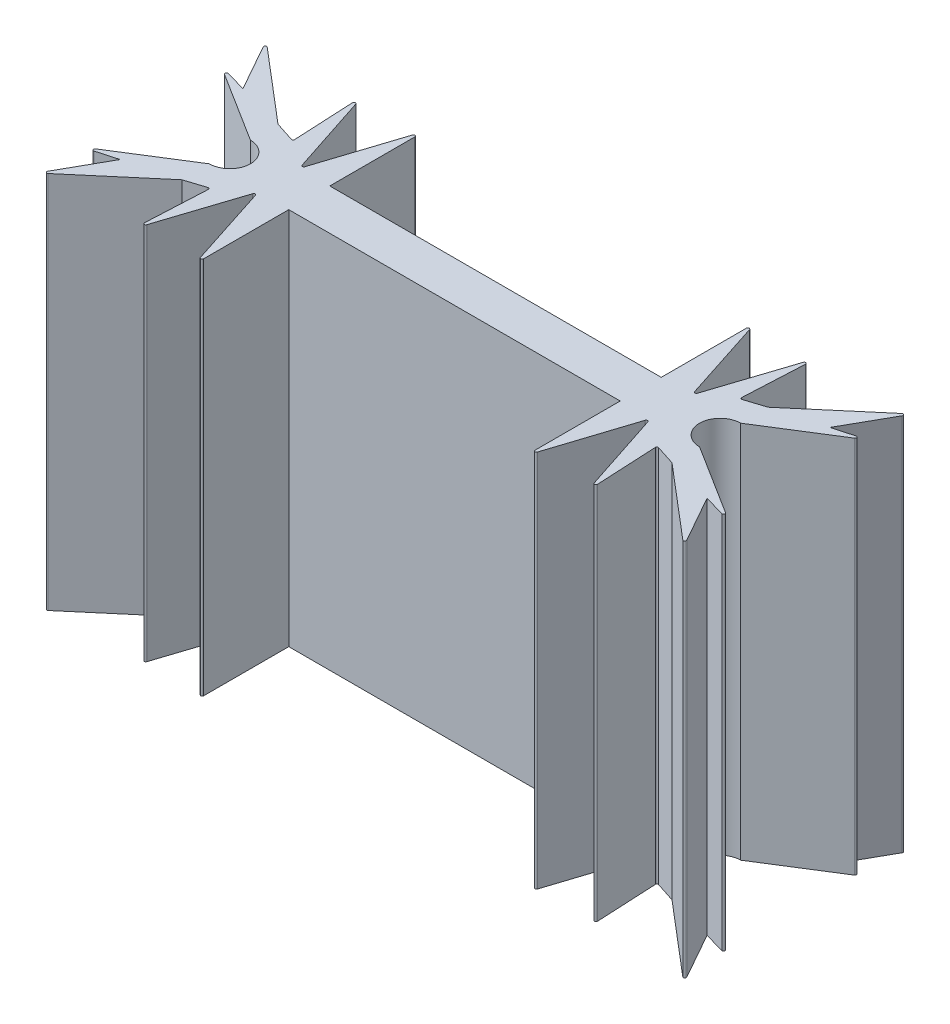
from build123d import *

# Parameters (mm, degrees)
EXTRUDE_1_DEPTH = 26.4


with BuildPart() as part:
    # Эскиз1 → Бобышка-Вытянуть1 (new body)
    with BuildSketch(Plane(origin=(0, 0, 0), x_dir=(1, 0, 0), z_dir=(0, 1, 0))):
        with BuildLine():
            Line((0, -7.366273292), (0, -1.430737225))
            Line((0, -1.430737225), (-23.119998808, -1.430737225))
            Line((-23.119998808, -1.430737225), (-23.119998808, -7.366273292))
            ThreePointArc((-23.119998808, -7.366273292), (-23.204411997, -7.465051079), (-23.315139834, -7.397065907))
            Line((-23.315139834, -7.397065907), (-25.151536602, -1.723086212))
            ThreePointArc((-25.151536602, -1.723086212), (-25.246516215, -1.653878958), (-25.341718752, -1.722779233))
            Line((-25.341718752, -1.722779233), (-27.163713043, -7.290838427))
            ThreePointArc((-27.163713043, -7.290838427), (-27.276953731, -7.358068766), (-27.358630238, -7.254761845))
            Line((-27.358630238, -7.254761845), (-27.147073457, -3.009330281))
            ThreePointArc((-27.147073457, -3.009330281), (-27.186129834, -2.924974677), (-27.277742143, -2.909212268))
            Line((-27.277742143, -2.909212268), (-28.656433819, -3.355429045))
            Line((-28.656433819, -3.355429045), (-33.693480219, -7.637416988))
            ThreePointArc((-33.693480219, -7.637416988), (-33.821863766, -7.638385786), (-33.84539196, -7.51217288))
            Line((-33.84539196, -7.51217288), (-32.027666378, -4.283069467))
            Line((-32.027666378, -4.283069467), (-33.457933536, -4.683052776))
            ThreePointArc((-33.457933536, -4.683052776), (-33.57629105, -4.627262362), (-33.538118808, -4.502106653))
            Line((-33.538118808, -4.502106653), (-28.656434415, -1.430737225))
            ThreePointArc((-28.656434415, -1.430737225), (-27.22569719, 0), (-28.656434415, 1.430737225))
            Line((-28.656434415, 1.430737225), (-33.538118808, 4.502106653))
            ThreePointArc((-33.538118808, 4.502106653), (-33.57629105, 4.627262362), (-33.457933536, 4.683052776))
            Line((-33.457933536, 4.683052776), (-32.027666378, 4.283069467))
            Line((-32.027666378, 4.283069467), (-33.84539196, 7.51217288))
            ThreePointArc((-33.84539196, 7.51217288), (-33.821862569, 7.638384319), (-33.693480241, 7.637416132))
            Line((-33.693480241, 7.637416132), (-28.656433494, 3.355428597))
            Line((-28.656433494, 3.355428597), (-27.277741782, 2.909211931))
            ThreePointArc((-27.277741782, 2.909211931), (-27.186129475, 2.924974348), (-27.147073104, 3.009329955))
            Line((-27.147073104, 3.009329955), (-27.358630229, 7.254761502))
            ThreePointArc((-27.358630229, 7.254761502), (-27.27695373, 7.35806843), (-27.163713037, 7.2908381))
            Line((-27.163713037, 7.2908381), (-25.341718295, 1.722779053))
            ThreePointArc((-25.341718295, 1.722779053), (-25.246515752, 1.653878786), (-25.151536145, 1.723086048))
            Line((-25.151536145, 1.723086048), (-23.315139837, 7.397065891))
            ThreePointArc((-23.315139837, 7.397065891), (-23.204412005, 7.465051072), (-23.119998808, 7.366273292))
            Line((-23.119998808, 7.366273292), (-23.119998808, 1.430737225))
            Line((-23.119998808, 1.430737225), (0, 1.430737225))
            Line((0, 1.430737225), (0, 7.366273292))
            ThreePointArc((0, 7.366273292), (0.084413196, 7.465051072), (0.195141029, 7.397065891))
            Line((0.195141029, 7.397065891), (2.031537337, 1.723086048))
            ThreePointArc((2.031537337, 1.723086048), (2.126516944, 1.653878786), (2.221719487, 1.722779053))
            Line((2.221719487, 1.722779053), (4.043714229, 7.2908381))
            ThreePointArc((4.043714229, 7.2908381), (4.156954922, 7.35806843), (4.238631421, 7.254761502))
            Line((4.238631421, 7.254761502), (4.027074296, 3.009329955))
            ThreePointArc((4.027074296, 3.009329955), (4.066130667, 2.924974348), (4.157742974, 2.909211931))
            Line((4.157742974, 2.909211931), (5.536434686, 3.355428597))
            Line((5.536434686, 3.355428597), (10.573481433, 7.637416132))
            ThreePointArc((10.573481433, 7.637416132), (10.701863761, 7.638384319), (10.725393152, 7.51217288))
            Line((10.725393152, 7.51217288), (8.90766757, 4.283069467))
            Line((8.90766757, 4.283069467), (10.337934728, 4.683052776))
            ThreePointArc((10.337934728, 4.683052776), (10.456292242, 4.627262362), (10.41812, 4.502106653))
            Line((10.41812, 4.502106653), (5.536435606, 1.430737225))
            ThreePointArc((5.536435606, 1.430737225), (4.105698382, 0), (5.536435606, -1.430737225))
            Line((5.536435606, -1.430737225), (10.41812, -4.502106653))
            ThreePointArc((10.41812, -4.502106653), (10.456292242, -4.627262362), (10.337934728, -4.683052776))
            Line((10.337934728, -4.683052776), (8.90766757, -4.283069467))
            Line((8.90766757, -4.283069467), (10.725393152, -7.51217288))
            ThreePointArc((10.725393152, -7.51217288), (10.701864958, -7.638385786), (10.573481411, -7.637416988))
            Line((10.573481411, -7.637416988), (5.536435011, -3.355429045))
            Line((5.536435011, -3.355429045), (4.157743335, -2.909212268))
            ThreePointArc((4.157743335, -2.909212268), (4.066131026, -2.924974677), (4.027074648, -3.009330281))
            Line((4.027074648, -3.009330281), (4.23863143, -7.254761845))
            ThreePointArc((4.23863143, -7.254761845), (4.156954922, -7.358068766), (4.043714235, -7.290838427))
            Line((4.043714235, -7.290838427), (2.221719944, -1.722779233))
            ThreePointArc((2.221719944, -1.722779233), (2.126517406, -1.653878958), (2.031537794, -1.723086212))
            Line((2.031537794, -1.723086212), (0.195141026, -7.397065907))
            ThreePointArc((0.195141026, -7.397065907), (0.084413188, -7.465051079), (0, -7.366273292))
        make_face()
    extrude(amount=EXTRUDE_1_DEPTH)


solid = part.part
